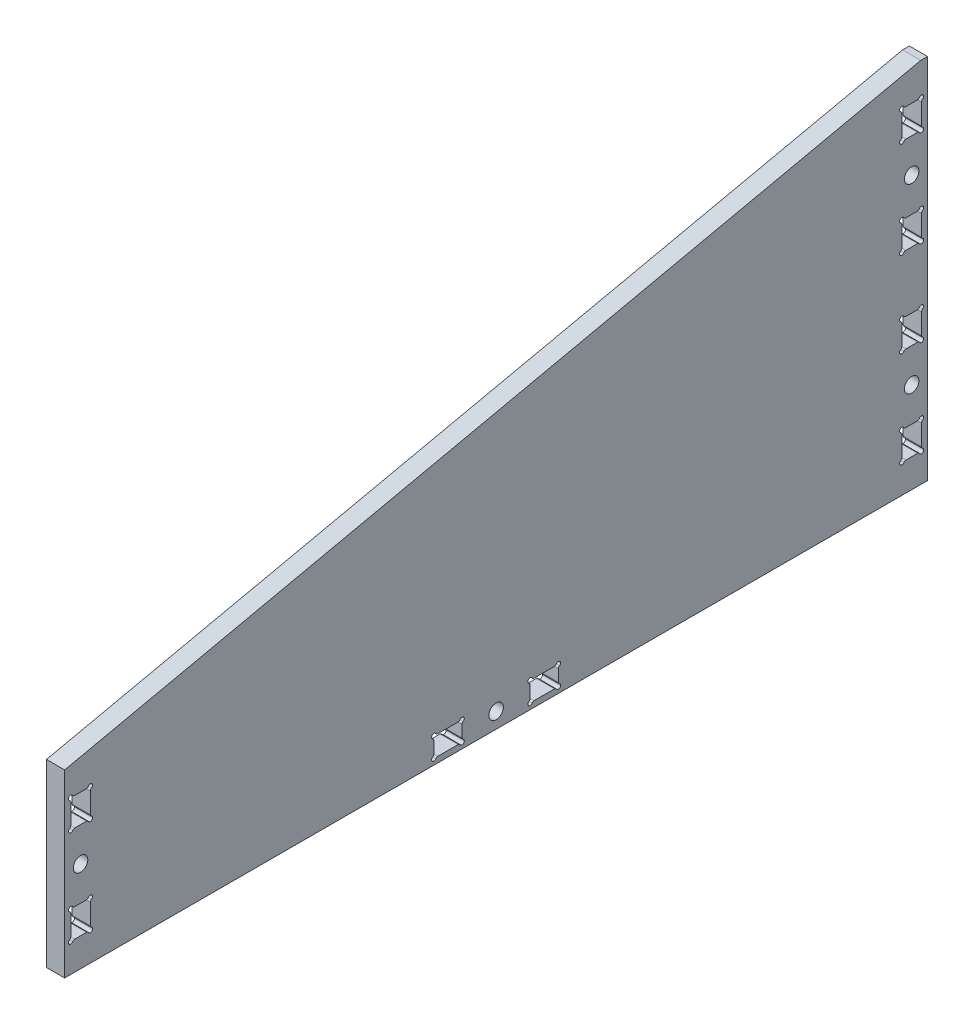
from build123d import *

# Parameters (mm, degrees)
CROQUIS1_R              = 1.6
SALIENTE_EXTRUIR1_DEPTH = 4


with BuildPart() as part:
    # Croquis1 → Saliente-Extruir1 (new body)
    with BuildSketch(Plane(origin=(0, 0, 0), x_dir=(0, 0, -1), z_dir=(1, 0, 0))):
        Polygon((93.689337425, 39.394454633), (-94.810766576, -1.653222282), (-94.810766576, -41.325385506), (95.189337425, -41.477791922), (95.189337425, 39.394454633), align=None)
        with BuildLine():
            ThreePointArc((-89.593826998, -35.276591354), (-89.776839283, -35.093579843), (-90.026838169, -35.026592779))
            Line((-90.026838169, -35.026592779), (-92.594705765, -35.026589144))
            ThreePointArc((-92.594705765, -35.026589144), (-92.844706526, -35.093576473), (-93.02771959, -35.276589864))
            ThreePointArc((-93.02771959, -35.276589864), (-93.814285223, -35.380144849), (-93.710734132, -34.593578704))
            ThreePointArc((-93.710734132, -34.593578704), (-93.527722621, -34.410566419), (-93.460735557, -34.160567532))
            Line((-93.460735557, -34.160567532), (-93.460734456, -29.692617936))
            ThreePointArc((-93.460734456, -29.692617936), (-93.527721764, -29.442617462), (-93.710734885, -29.259604529))
            ThreePointArc((-93.710734885, -29.259604529), (-93.814290016, -28.4730395), (-93.027724219, -28.576588797))
            ThreePointArc((-93.027724219, -28.576588797), (-92.844711931, -28.759599405), (-92.594713581, -28.826586014))
            Line((-92.594713581, -28.826586014), (-90.026843985, -28.826588364))
            ThreePointArc((-90.026843985, -28.826588364), (-89.776843527, -28.759601065), (-89.593830596, -28.576587965))
            ThreePointArc((-89.593830596, -28.576587965), (-88.807264887, -28.473033563), (-88.91081656, -29.259599631))
            ThreePointArc((-88.91081656, -29.259599631), (-89.093824053, -29.442613362), (-89.160807855, -29.692611239))
            Line((-89.160807855, -29.692611239), (-89.160808378, -34.160562987))
            ThreePointArc((-89.160808378, -34.160562987), (-89.093824591, -34.410562336), (-88.910815838, -34.593576812))
            ThreePointArc((-88.910815838, -34.593576812), (-88.807260852, -35.380142445), (-89.593826998, -35.276591354))
        make_face(mode=Mode.SUBTRACT)
        with Locations((-91.310766576, -21.326585919)):
            Circle(CROQUIS1_R, mode=Mode.SUBTRACT)
        with BuildLine():
            ThreePointArc((-7.743738947, -40.376497286), (-7.926751533, -40.193485651), (-8.176750783, -40.126498786))
            Line((-8.176750783, -40.126498786), (-12.64470038, -40.126498786))
            ThreePointArc((-12.64470038, -40.126498786), (-12.894701046, -40.193486469), (-13.077713851, -40.376500118))
            ThreePointArc((-13.077713851, -40.376500118), (-13.864279337, -40.480056217), (-13.76072936, -39.693489925))
            ThreePointArc((-13.76072936, -39.693489925), (-13.577718107, -39.510477381), (-13.510731397, -39.2604784))
            Line((-13.510731397, -39.2604784), (-13.510731397, -36.692610803))
            ThreePointArc((-13.510731397, -36.692610803), (-13.57771908, -36.442610137), (-13.76073273, -36.259597332))
            ThreePointArc((-13.76073273, -36.259597332), (-13.864288828, -35.473031846), (-13.077722536, -35.576581824))
            ThreePointArc((-13.077722536, -35.576581824), (-12.894709992, -35.759593076), (-12.644711011, -35.826579786))
            Line((-12.644711011, -35.826579786), (-8.176761415, -35.826579786))
            ThreePointArc((-8.176761415, -35.826579786), (-7.926761002, -35.75959225), (-7.743748236, -35.576578961))
            ThreePointArc((-7.743748236, -35.576578961), (-6.957183302, -35.47302311), (-7.060731879, -36.259589002))
            ThreePointArc((-7.060731879, -36.259589002), (-7.24374232, -36.442601458), (-7.310728701, -36.692599869))
            Line((-7.310728701, -36.692599869), (-7.310728701, -39.260469465))
            ThreePointArc((-7.310728701, -39.260469465), (-7.243741173, -39.510469862), (-7.060727906, -39.693482626))
            ThreePointArc((-7.060727906, -39.693482626), (-6.957172784, -40.48004824), (-7.743738947, -40.376497286))
        make_face(mode=Mode.SUBTRACT)
        with Locations((0.189270603, -37.976542443)):
            Circle(CROQUIS1_R, mode=Mode.SUBTRACT)
        with BuildLine():
            Line((-93.460730334, -12.960567532), (-93.460729233, -8.492617936))
            ThreePointArc((-93.460729233, -8.492617936), (-93.5277176, -8.242615961), (-93.710733044, -8.059602911))
            ThreePointArc((-93.710733044, -8.059602911), (-93.814284329, -7.273030997), (-93.027712913, -7.37658607))
            ThreePointArc((-93.027712913, -7.37658607), (-92.844700263, -7.559598756), (-92.594700323, -7.626586091))
            Line((-92.594700323, -7.626586091), (-90.026830727, -7.626586723))
            ThreePointArc((-90.026830727, -7.626586723), (-89.776830688, -7.559599474), (-89.593817938, -7.376586785))
            ThreePointArc((-89.593817938, -7.376586785), (-88.80725292, -7.273032418), (-88.910802665, -8.059598045))
            ThreePointArc((-88.910802665, -8.059598045), (-89.093816721, -8.242609964), (-89.160805373, -8.492610019))
            Line((-89.160805373, -8.492610019), (-89.160805896, -12.960561574))
            ThreePointArc((-89.160805896, -12.960561574), (-89.093821761, -13.210560867), (-88.910812722, -13.393575107))
            ThreePointArc((-88.910812722, -13.393575107), (-88.807256817, -14.180140618), (-89.593823083, -14.076590448))
            ThreePointArc((-89.593823083, -14.076590448), (-89.776835582, -13.89357915), (-90.026834547, -13.826592379))
            Line((-90.026834547, -13.826592379), (-92.594702143, -13.826591746))
            ThreePointArc((-92.594702143, -13.826591746), (-92.844702037, -13.893578911), (-93.027714765, -14.076591393))
            ThreePointArc((-93.027714765, -14.076591393), (-93.814280171, -14.180144913), (-93.710728798, -13.393579225))
            ThreePointArc((-93.710728798, -13.393579225), (-93.527717219, -13.210566695), (-93.460730334, -12.960567532))
        make_face(mode=Mode.SUBTRACT)
        with BuildLine():
            ThreePointArc((14.139268599, -36.259584603), (13.956255959, -36.442597298), (13.889268686, -36.692597255))
            Line((13.889268686, -36.692597255), (13.889268686, -39.260466851))
            ThreePointArc((13.889268686, -39.260466851), (13.956255997, -39.510466873), (14.13926873, -39.693479579))
            ThreePointArc((14.13926873, -39.693479579), (14.242822973, -40.48004489), (13.456257189, -40.376494239))
            ThreePointArc((13.456257189, -40.376494239), (13.273244636, -40.193482912), (13.023245603, -40.126496172))
            Line((13.023245603, -40.126496172), (8.555296007, -40.126496172))
            ThreePointArc((8.555296007, -40.126496172), (8.30529534, -40.193483855), (8.122282535, -40.376497504))
            ThreePointArc((8.122282535, -40.376497504), (7.33571705, -40.480053603), (7.439267027, -39.693487311))
            ThreePointArc((7.439267027, -39.693487311), (7.622278279, -39.510474767), (7.689264989, -39.260475786))
            Line((7.689264989, -39.260475786), (7.689264989, -36.69260819))
            ThreePointArc((7.689264989, -36.69260819), (7.622277762, -36.442608313), (7.439265235, -36.25959563))
            ThreePointArc((7.439265235, -36.25959563), (7.335711521, -35.47303025), (8.122277235, -35.576581428))
            ThreePointArc((8.122277235, -35.576581428), (8.30528981, -35.759592962), (8.555288989, -35.826579786))
            Line((8.555288989, -35.826579786), (13.023238585, -35.826579786))
            ThreePointArc((13.023238585, -35.826579786), (13.273240544, -35.759591357), (13.456253549, -35.576575869))
            ThreePointArc((13.456253549, -35.576575869), (14.242820268, -35.473016926), (14.139268599, -36.259584603))
        make_face(mode=Mode.SUBTRACT)
        with BuildLine():
            ThreePointArc((89.289376806, -34.743579058), (89.472388058, -34.560566514), (89.539374768, -34.310567532))
            Line((89.539374768, -34.310567532), (89.539374768, -29.842617936))
            ThreePointArc((89.539374768, -29.842617936), (89.472387232, -29.592617524), (89.289373943, -29.409604758))
            ThreePointArc((89.289373943, -29.409604758), (89.185818092, -28.623039824), (89.972383984, -28.726588401))
            ThreePointArc((89.972383984, -28.726588401), (90.15539644, -28.909598842), (90.405394851, -28.976585222))
            Line((90.405394851, -28.976585222), (92.973264447, -28.976585222))
            ThreePointArc((92.973264447, -28.976585222), (93.223264844, -28.909597695), (93.406277608, -28.726584428))
            ThreePointArc((93.406277608, -28.726584428), (94.192843222, -28.623029306), (94.089292268, -29.409595469))
            ThreePointArc((94.089292268, -29.409595469), (93.906280633, -29.592608055), (93.839293768, -29.842607305))
            Line((93.839293768, -29.842607305), (93.839293768, -34.310556901))
            ThreePointArc((93.839293768, -34.310556901), (93.906281451, -34.560557567), (94.0892951, -34.743570372))
            ThreePointArc((94.0892951, -34.743570372), (94.192851199, -35.530135858), (93.406284907, -35.426585881))
            ThreePointArc((93.406284907, -35.426585881), (93.223272363, -35.243574629), (92.973273382, -35.176587919))
            Line((92.973273382, -35.176587919), (90.405405786, -35.176587919))
            ThreePointArc((90.405405786, -35.176587919), (90.15540512, -35.243575601), (89.972392315, -35.426589251))
            ThreePointArc((89.972392315, -35.426589251), (89.185826829, -35.53014535), (89.289376806, -34.743579058))
        make_face(mode=Mode.SUBTRACT)
        with Locations((91.689337425, -21.476585919)):
            Circle(CROQUIS1_R, mode=Mode.SUBTRACT)
        with BuildLine():
            ThreePointArc((93.406282294, -14.226589495), (93.223269749, -14.043578242), (92.973270768, -13.976591532))
            Line((92.973270768, -13.976591532), (90.405403172, -13.976591532))
            ThreePointArc((90.405403172, -13.976591532), (90.155403295, -14.043578759), (89.972390612, -14.226591286))
            ThreePointArc((89.972390612, -14.226591286), (89.185825232, -14.330145), (89.28937641, -13.543579286))
            ThreePointArc((89.28937641, -13.543579286), (89.472387944, -13.360566711), (89.539374768, -13.110567532))
            Line((89.539374768, -13.110567532), (89.539374768, -8.642617936))
            ThreePointArc((89.539374768, -8.642617936), (89.472386339, -8.392615978), (89.289370851, -8.209602973))
            ThreePointArc((89.289370851, -8.209602973), (89.185811908, -7.423036253), (89.972379585, -7.526587922))
            ThreePointArc((89.972379585, -7.526587922), (90.15539228, -7.709600563), (90.405392237, -7.776587836))
            Line((90.405392237, -7.776587836), (92.973261833, -7.776587836))
            ThreePointArc((92.973261833, -7.776587836), (93.223261856, -7.709600525), (93.406274561, -7.526587791))
            ThreePointArc((93.406274561, -7.526587791), (94.192839872, -7.423033549), (94.089289221, -8.209599333))
            ThreePointArc((94.089289221, -8.209599333), (93.906277894, -8.392611885), (93.839291154, -8.642610919))
            Line((93.839291154, -8.642610919), (93.839291154, -13.110560515))
            ThreePointArc((93.839291154, -13.110560515), (93.906278837, -13.360561181), (94.089292487, -13.543573986))
            ThreePointArc((94.089292487, -13.543573986), (94.192848585, -14.330139472), (93.406282294, -14.226589495))
        make_face(mode=Mode.SUBTRACT)
        with BuildLine():
            ThreePointArc((89.289376806, 5.256415352), (89.472388058, 5.439427896), (89.539374768, 5.689426877))
            Line((89.539374768, 5.689426877), (89.539374768, 10.157376473))
            ThreePointArc((89.539374768, 10.157376473), (89.472387232, 10.407376886), (89.289373943, 10.590389652))
            ThreePointArc((89.289373943, 10.590389652), (89.185818092, 11.376954586), (89.972383984, 11.273406009))
            ThreePointArc((89.972383984, 11.273406009), (90.15539644, 11.090395568), (90.405394851, 11.023409187))
            Line((90.405394851, 11.023409187), (92.973264447, 11.023409187))
            ThreePointArc((92.973264447, 11.023409187), (93.223264844, 11.090396715), (93.406277608, 11.273409982))
            ThreePointArc((93.406277608, 11.273409982), (94.192843222, 11.376965104), (94.089292268, 10.590398941))
            ThreePointArc((94.089292268, 10.590398941), (93.906280633, 10.407386355), (93.839293768, 10.157387105))
            Line((93.839293768, 10.157387105), (93.839293768, 5.689437508))
            ThreePointArc((93.839293768, 5.689437508), (93.906281451, 5.439436842), (94.0892951, 5.256424037))
            ThreePointArc((94.0892951, 5.256424037), (94.192851199, 4.469858551), (93.406284907, 4.573408529))
            ThreePointArc((93.406284907, 4.573408529), (93.223272363, 4.756419781), (92.973273382, 4.823406491))
            Line((92.973273382, 4.823406491), (90.405405786, 4.823406491))
            ThreePointArc((90.405405786, 4.823406491), (90.15540512, 4.756418808), (89.972392315, 4.573405159))
            ThreePointArc((89.972392315, 4.573405159), (89.185826829, 4.46984906), (89.289376806, 5.256415352))
        make_face(mode=Mode.SUBTRACT)
        with Locations((91.689337425, 18.523408491)):
            Circle(CROQUIS1_R, mode=Mode.SUBTRACT)
        with BuildLine():
            ThreePointArc((93.406282294, 25.773404915), (93.223269749, 25.956416167), (92.973270768, 26.023402877))
            Line((92.973270768, 26.023402877), (90.405403172, 26.023402877))
            ThreePointArc((90.405403172, 26.023402877), (90.155403295, 25.95641565), (89.972390612, 25.773403123))
            ThreePointArc((89.972390612, 25.773403123), (89.185825232, 25.669849409), (89.28937641, 26.456415123))
            ThreePointArc((89.28937641, 26.456415123), (89.472387944, 26.639427698), (89.539374768, 26.889426877))
            Line((89.539374768, 26.889426877), (89.539374768, 31.357376473))
            ThreePointArc((89.539374768, 31.357376473), (89.472386339, 31.607378432), (89.289370851, 31.790391437))
            ThreePointArc((89.289370851, 31.790391437), (89.185811908, 32.576958156), (89.972379585, 32.473406487))
            ThreePointArc((89.972379585, 32.473406487), (90.15539228, 32.290393847), (90.405392237, 32.223406574))
            Line((90.405392237, 32.223406574), (92.973261833, 32.223406574))
            ThreePointArc((92.973261833, 32.223406574), (93.223261856, 32.290393885), (93.406274561, 32.473406618))
            ThreePointArc((93.406274561, 32.473406618), (94.192839872, 32.576960861), (94.089289221, 31.790395077))
            ThreePointArc((94.089289221, 31.790395077), (93.906277894, 31.607382524), (93.839291154, 31.357383491))
            Line((93.839291154, 31.357383491), (93.839291154, 26.889433895))
            ThreePointArc((93.839291154, 26.889433895), (93.906278837, 26.639433229), (94.089292487, 26.456420424))
            ThreePointArc((94.089292487, 26.456420424), (94.192848585, 25.669854938), (93.406282294, 25.773404915))
        make_face(mode=Mode.SUBTRACT)
    extrude(amount=SALIENTE_EXTRUIR1_DEPTH)


solid = part.part
